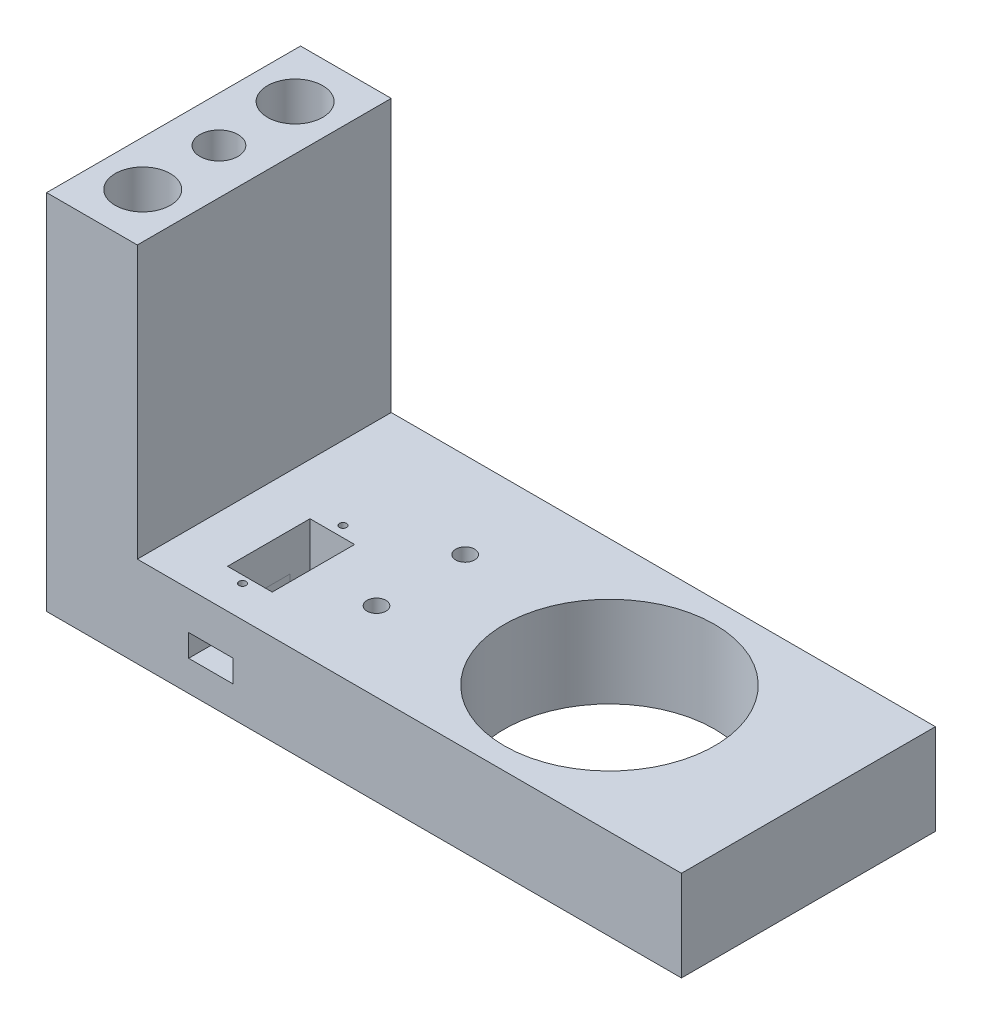
from build123d import *

# Parameters (mm, degrees)
SKETCH1_W               = 25
SKETCH1_H               = 70
SKETCH1_R               = 7.6
SKETCH1_R_2             = 5.25
BOSS_EXTRUDE2_DEPTH     = 100
SKETCH1_12_R            = 1.575
CUT_EXTRUDE5_DEPTH      = 12.8
SKETCH1_27_R            = 11.15
CORTAR_EXTRUIR1_DEPTH   = 3.5
CROQUIS1_W              = 70
CROQUIS1_H              = 25
SALIENTE_EXTRUIR1_DEPTH = 150
CROQUIS4_R              = 29
CORTAR_EXTRUIR2_DEPTH   = 30
CUT_EXTRUDE6_START      = -25
CROQUIS4_3_W            = 12.3
CROQUIS4_3_H            = 22.718001441
CUT_EXTRUDE6_DEPTH      = 22
CUT_EXTRUDE7_START      = -25
CROQUIS4_4_R            = 1
CUT_EXTRUDE7_DEPTH      = 6
SKETCH2_W               = 12.2
SKETCH2_H               = 6.16
CUT_EXTRUDE11_DEPTH     = 28
CROQUIS5_R              = 2.6
CORTAR_EXTRUIR3_DEPTH   = 50


with BuildPart() as part:
    # Sketch1 → Boss-Extrude2 (new body)
    with BuildSketch(Plane(origin=(0, 0, 0), x_dir=(1, 0, 0), z_dir=(0, 1, 0))):
        Rectangle(SKETCH1_W, SKETCH1_H)
        with Locations((0, 21)):
            Circle(SKETCH1_R, mode=Mode.SUBTRACT)
        with Locations((0, -21)):
            Circle(SKETCH1_R, mode=Mode.SUBTRACT)
        Circle(SKETCH1_R_2, mode=Mode.SUBTRACT)
    extrude(amount=BOSS_EXTRUDE2_DEPTH)

    # Sketch1_12 → Cut-Extrude5 (cut)
    with BuildSketch(Plane(origin=(0, 0, 0), x_dir=(1, 0, 0), z_dir=(0, 1, 0))):
        with Locations((0, 8.193732966)):
            Circle(SKETCH1_12_R)
        with Locations((8.193732966, 0)):
            Circle(SKETCH1_12_R)
        with Locations((0, -8.193732966)):
            Circle(SKETCH1_12_R)
        with Locations((-8.193732966, 0)):
            Circle(SKETCH1_12_R)
    extrude(amount=CUT_EXTRUDE5_DEPTH, mode=Mode.SUBTRACT)

    # Sketch1_27 → Cortar-Extruir1 (cut)
    with BuildSketch(Plane(origin=(0, 0, 0), x_dir=(1, 0, 0), z_dir=(0, 1, 0))):
        Circle(SKETCH1_27_R)
    extrude(amount=CORTAR_EXTRUIR1_DEPTH, mode=Mode.SUBTRACT)

    # Croquis1 → Saliente-Extruir1 (add)
    with BuildSketch(Plane(origin=(12.5, 0, 0), x_dir=(0, 0, -1), z_dir=(1, 0, 0))):
        with Locations((0, 12.5)):
            Rectangle(CROQUIS1_W, CROQUIS1_H)
    extrude(amount=SALIENTE_EXTRUIR1_DEPTH)

    # Croquis4 → Cortar-Extruir2 (cut)
    with BuildSketch(Plane.XZ):
        with Locations((107.66, 0)):
            Circle(CROQUIS4_R)
    extrude(amount=-CORTAR_EXTRUIR2_DEPTH, mode=Mode.SUBTRACT)

    # Croquis4_3 → Cut-Extrude6 (cut)
    with BuildSketch(Plane.XZ.offset(CUT_EXTRUDE6_START)):
        with Locations((32.807294184, 12.912589049)):
            Rectangle(CROQUIS4_3_W, CROQUIS4_3_H)
    extrude(amount=CUT_EXTRUDE6_DEPTH, mode=Mode.SUBTRACT)

    # Croquis4_4 → Cut-Extrude7 (cut)
    with BuildSketch(Plane.XZ.offset(CUT_EXTRUDE7_START)):
        with Locations((32.807294184, -1.398410231)):
            Circle(CROQUIS4_4_R)
        with Locations((32.807294184, 26.301614952)):
            Circle(CROQUIS4_4_R)
    extrude(amount=CUT_EXTRUDE7_DEPTH, mode=Mode.SUBTRACT)

    # Sketch2 → Cut-Extrude11 (cut)
    with BuildSketch(Plane.XY.offset(35)):
        with Locations((32.75, 11.48)):
            Rectangle(SKETCH2_W, SKETCH2_H)
    extrude(amount=-CUT_EXTRUDE11_DEPTH, mode=Mode.SUBTRACT)

    # Croquis5 → Cortar-Extruir3 (cut)
    with BuildSketch(Plane(origin=(0, 25, 0), x_dir=(1, 0, 0), z_dir=(0, 1, 0))):
        with Locations((56.60021437, -13.16922633)):
            Circle(CROQUIS5_R)
        with Locations((56.60021437, 11.27722458)):
            Circle(CROQUIS5_R)
    extrude(amount=-CORTAR_EXTRUIR3_DEPTH, mode=Mode.SUBTRACT)


solid = part.part
